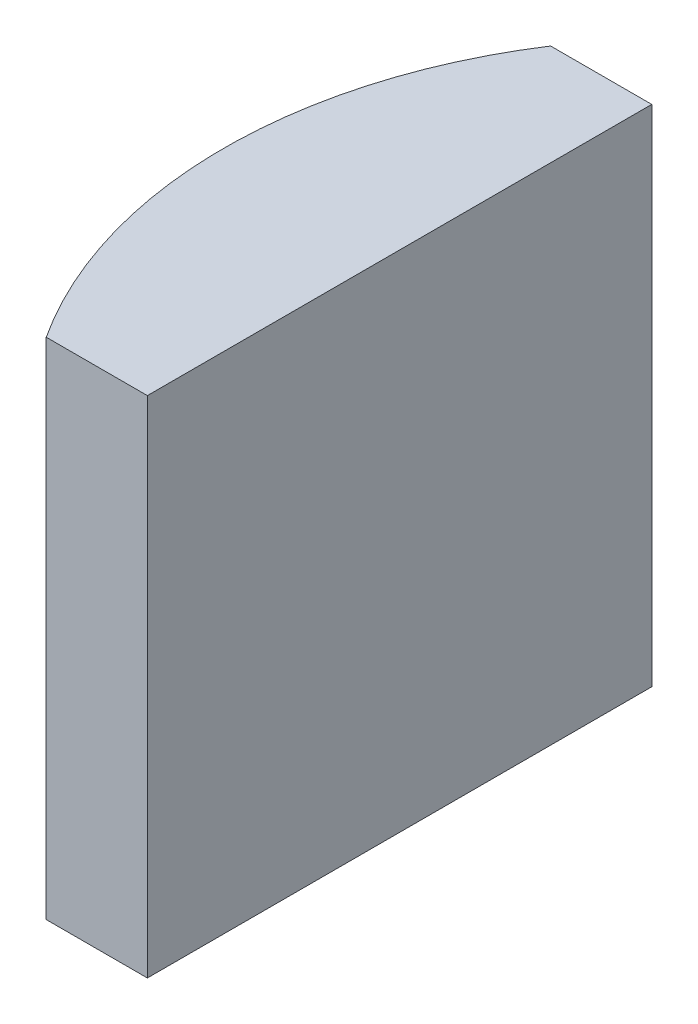
from build123d import *

# Parameters (mm, degrees)
EXTRUDE_1_DEPTH = 10


with BuildPart() as part:
    # 草图1 → 凸台-拉伸1 (new body)
    with BuildSketch(Plane(origin=(0, 0, 0), x_dir=(1, 0, 0), z_dir=(0, 1, 0))):
        with BuildLine():
            Line((-3.319794036, 5), (-1.314795665, 5))
            Line((-1.314795665, 5), (-1.314795665, -5))
            Line((-1.314795665, -5), (-3.319794036, -5))
            ThreePointArc((-3.319794036, -5), (-4.804795665, 0), (-3.319794036, 5))
        make_face()
    extrude(amount=EXTRUDE_1_DEPTH)


solid = part.part
